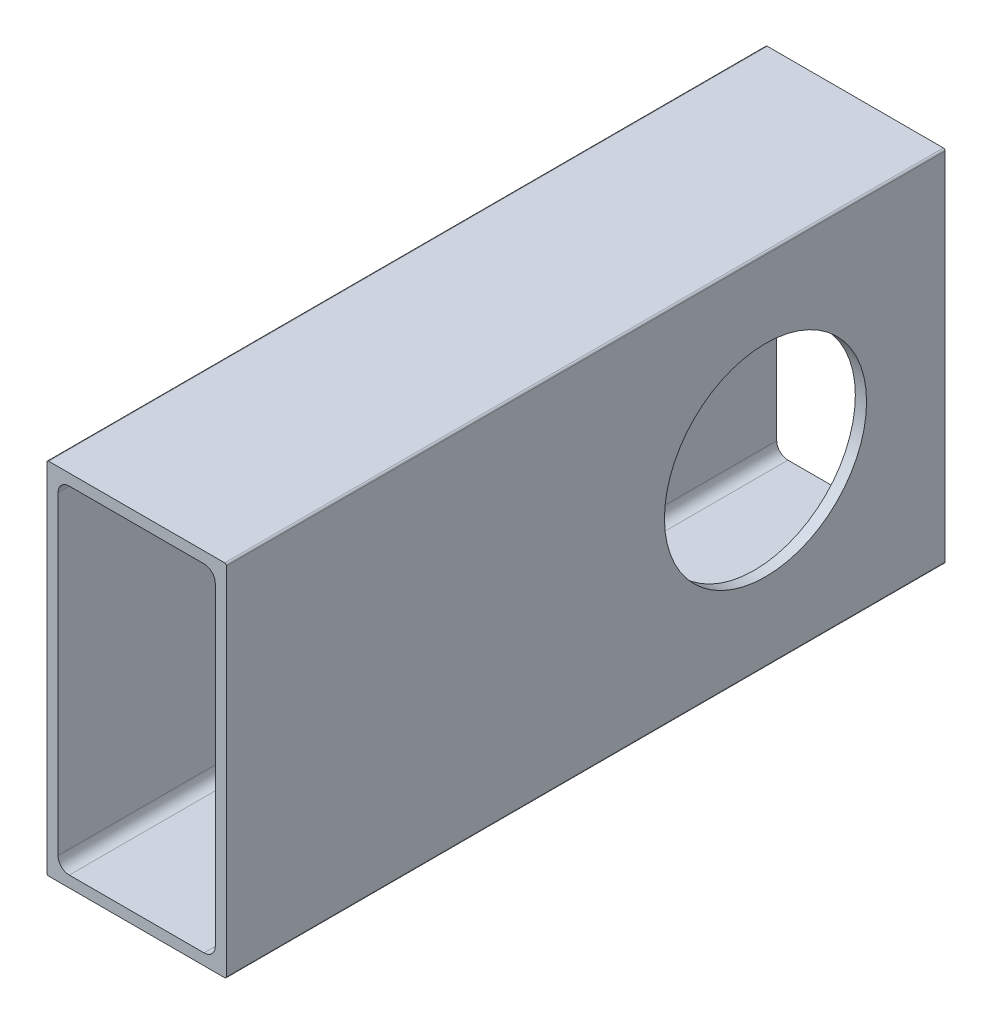
from build123d import *

# Parameters (mm, degrees)
BOSS_EXTRUDE1_DEPTH = 101.6
SKETCH2_R           = 14.2875
CUT_EXTRUDE1_DEPTH  = 50.8


with BuildPart() as part:
    # Sketch1 → Boss-Extrude1 (new body)
    with BuildSketch(Plane(origin=(0, 0, 0), x_dir=(-1, 0, 0), z_dir=(0, 0, -1))):
        with BuildLine():
            Line((-12.7, 25.146), (-12.7, -25.146))
            ThreePointArc((-12.7, -25.146), (-12.625605122, -25.325605122), (-12.446, -25.4))
            Line((-12.446, -25.4), (12.446, -25.4))
            ThreePointArc((12.446, -25.4), (12.625605122, -25.325605122), (12.7, -25.146))
            Line((12.7, -25.146), (12.7, 25.146))
            ThreePointArc((12.7, 25.146), (12.625605122, 25.325605122), (12.446, 25.4))
            Line((12.446, 25.4), (-12.446, 25.4))
            ThreePointArc((-12.446, 25.4), (-12.625605122, 25.325605122), (-12.7, 25.146))
        make_face()
        with BuildLine():
            Line((-11.1125, -22.225), (-11.1125, 22.225))
            ThreePointArc((-11.1125, 22.225), (-10.647532015, 23.347532015), (-9.525, 23.8125))
            Line((-9.525, 23.8125), (9.525, 23.8125))
            ThreePointArc((9.525, 23.8125), (10.647532015, 23.347532015), (11.1125, 22.225))
            Line((11.1125, 22.225), (11.1125, -22.225))
            ThreePointArc((11.1125, -22.225), (10.647532015, -23.347532015), (9.525, -23.8125))
            Line((9.525, -23.8125), (-9.525, -23.8125))
            ThreePointArc((-9.525, -23.8125), (-10.647532015, -23.347532015), (-11.1125, -22.225))
        make_face(mode=Mode.SUBTRACT)
    extrude(amount=-BOSS_EXTRUDE1_DEPTH)

    # Sketch2 → Cut-Extrude1 (cut)
    with BuildSketch(Plane.ZY.offset(12.7)):
        with Locations((25.4, 0)):
            Circle(SKETCH2_R)
    extrude(amount=-CUT_EXTRUDE1_DEPTH, mode=Mode.SUBTRACT)


solid = part.part
